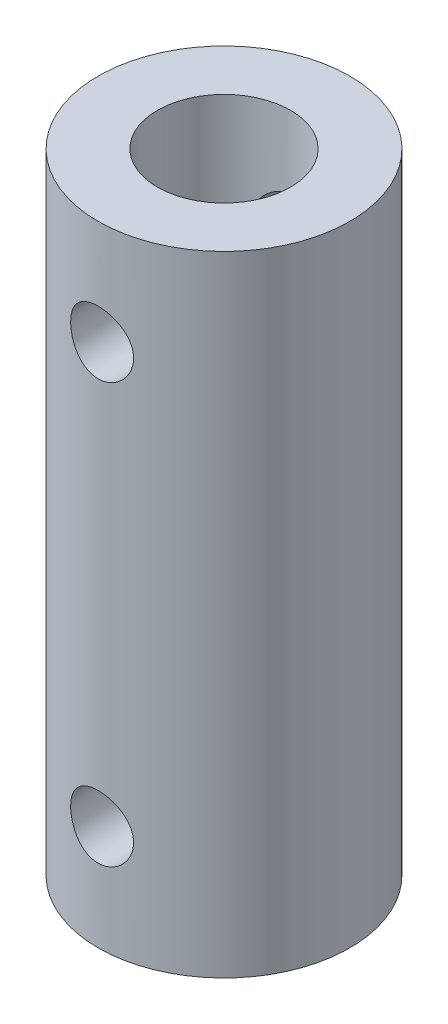
from build123d import *

# Parameters (mm, degrees)
SKETCH1_R               = 6
BOSS_EXTRUDE1_DEPTH     = 30
SKETCH2_R               = 3.175
CUT_EXTRUDE1_DEPTH      = 1
CUT_EXTRUDE1_DEPTH_BACK = 31
SKETCH4_R               = 1.5
CUT_EXTRUDE4_DEPTH      = 7
CUT_EXTRUDE4_DEPTH_BACK = 7


with BuildPart() as part:
    # Sketch1 → Boss-Extrude1 (new body)
    with BuildSketch(Plane(origin=(0, 0, 0), x_dir=(1, 0, 0), z_dir=(0, 1, 0))):
        Circle(SKETCH1_R)
    extrude(amount=BOSS_EXTRUDE1_DEPTH)

    # Sketch2 → Cut-Extrude1 (cut, two sides)
    with BuildSketch(Plane(origin=(0, 30, 0), x_dir=(1, 0, 0), z_dir=(0, 1, 0))) as cut_extrude1_sk:
        Circle(SKETCH2_R)
    extrude(amount=CUT_EXTRUDE1_DEPTH, mode=Mode.SUBTRACT)
    extrude(cut_extrude1_sk.sketch, amount=-CUT_EXTRUDE1_DEPTH_BACK, mode=Mode.SUBTRACT)

    # Sketch4 → Cut-Extrude4 (cut, two sides)
    with BuildSketch(Plane.XY) as cut_extrude4_sk:
        with Locations((0, 25)):
            Circle(SKETCH4_R)
        with Locations((0, 5)):
            Circle(SKETCH4_R)
    extrude(amount=CUT_EXTRUDE4_DEPTH, mode=Mode.SUBTRACT)
    extrude(cut_extrude4_sk.sketch, amount=-CUT_EXTRUDE4_DEPTH_BACK, mode=Mode.SUBTRACT)


solid = part.part
